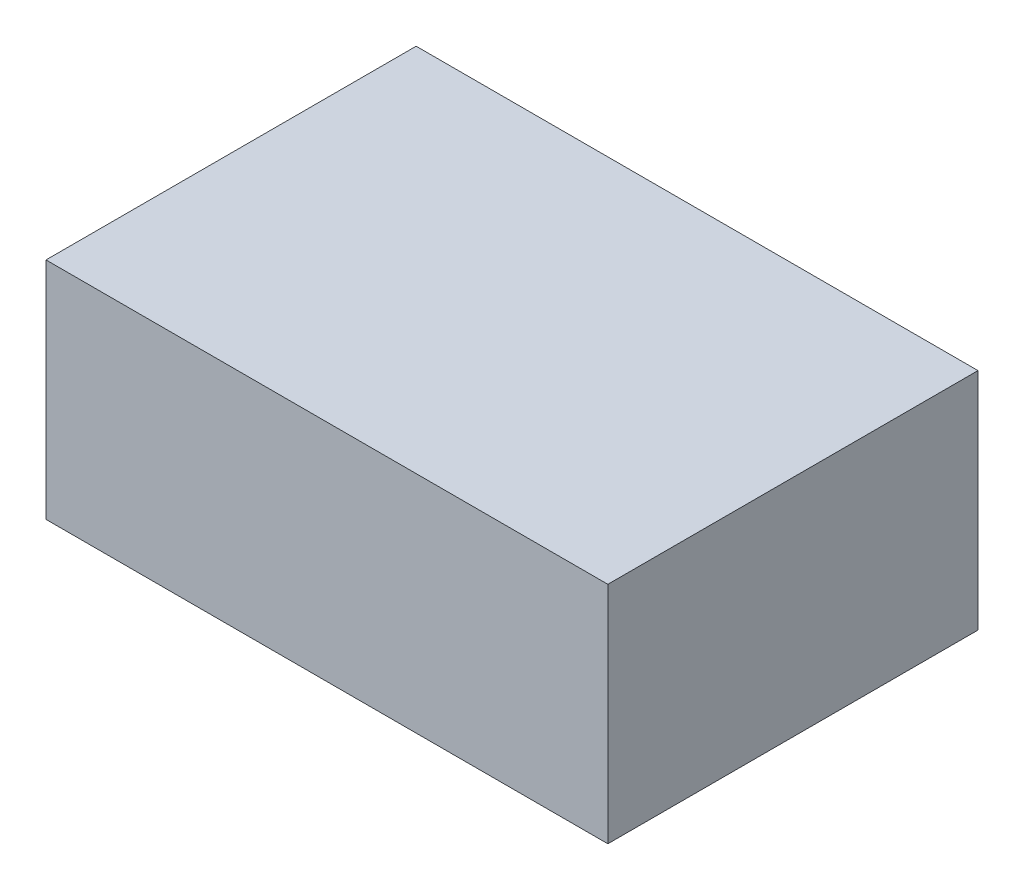
from build123d import *

# Parameters (mm, degrees)
SKETCH1_W           = 85
SKETCH1_H           = 56
BOSS_EXTRUDE1_DEPTH = 34


with BuildPart() as part:
    # Sketch1 → Boss-Extrude1 (new body)
    with BuildSketch(Plane(origin=(0, 0, 0), x_dir=(1, 0, 0), z_dir=(0, 1, 0))):
        Rectangle(SKETCH1_W, SKETCH1_H)
    extrude(amount=BOSS_EXTRUDE1_DEPTH)


solid = part.part
